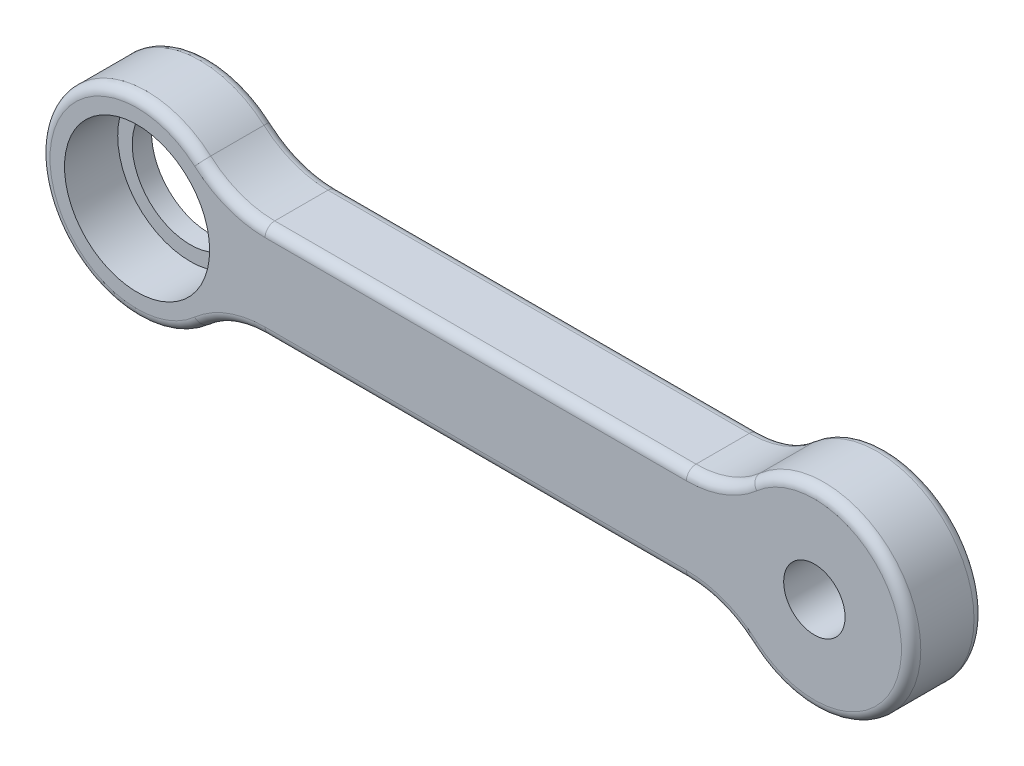
from build123d import *

# Parameters (mm, degrees)
BOSS_EXTRUDE1_DEPTH = 7.5
SKETCH2_R           = 7.5
CUT_EXTRUDE1_DEPTH  = 5.5
SKETCH3_R           = 6
CUT_EXTRUDE2_DEPTH  = 3
SKETCH4_R           = 3.175
CUT_EXTRUDE3_DEPTH  = 8.5
FILLET1_R           = 1


with BuildPart() as part:
    # Sketch1 → Boss-Extrude1 (new body)
    with BuildSketch(Plane.XY):
        with BuildLine():
            Line((-21.771243445, 5), (21.771243445, 5))
            ThreePointArc((21.771243445, 5), (25.306777351, 5.645856533), (28.385621722, 7.5))
            ThreePointArc((28.385621722, 7.5), (45, 0), (28.385621722, -7.5))
            ThreePointArc((28.385621722, -7.5), (25.306777351, -5.645856533), (21.771243445, -5))
            Line((21.771243445, -5), (-21.771243445, -5))
            ThreePointArc((-21.771243445, -5), (-25.306777351, -5.645856533), (-28.385621722, -7.5))
            ThreePointArc((-28.385621722, -7.5), (-45, 0), (-28.385621722, 7.5))
            ThreePointArc((-28.385621722, 7.5), (-25.306777351, 5.645856533), (-21.771243445, 5))
        make_face()
    extrude(amount=BOSS_EXTRUDE1_DEPTH)

    # Sketch2 → Cut-Extrude1 (cut)
    with BuildSketch(Plane.XY.offset(7.5)):
        with Locations((-35, 0)):
            Circle(SKETCH2_R)
    extrude(amount=-CUT_EXTRUDE1_DEPTH, mode=Mode.SUBTRACT)

    # Sketch3 → Cut-Extrude2 (cut, through all)
    with BuildSketch(Plane.XY.offset(2)):
        with Locations((-35, 0)):
            Circle(SKETCH3_R)
    extrude(amount=-CUT_EXTRUDE2_DEPTH, mode=Mode.SUBTRACT)

    # Sketch4 → Cut-Extrude3 (cut, through all)
    with BuildSketch(Plane(origin=(0, 0, 0), x_dir=(-1, 0, 0), z_dir=(0, 0, -1))):
        with Locations((-35, 0)):
            Circle(SKETCH4_R)
    extrude(amount=-CUT_EXTRUDE3_DEPTH, mode=Mode.SUBTRACT)

    # Fillet1
    fillet1_edges = [part.edges().sort_by_distance(p)[0] for p in [
        (25.306777351, 5.645856533, 7.5),
        (45, 0, 0),
        (25.306777351, -5.645856533, 0),
        (0, 5, 7.5),
        (-25.306777351, 5.645856533, 7.5),
        (-45, 0, 7.5),
        (-25.306777351, -5.645856533, 7.5),
        (0, -5, 7.5),
        (25.306777351, -5.645856533, 7.5),
        (45, 0, 7.5),
        (0, -5, 0),
        (-25.306777351, -5.645856533, 0),
        (-45, 0, 0),
        (-25.306777351, 5.645856533, 0),
        (0, 5, 0),
        (25.306777351, 5.645856533, 0),
    ]]
    fillet(fillet1_edges, radius=FILLET1_R)


solid = part.part
